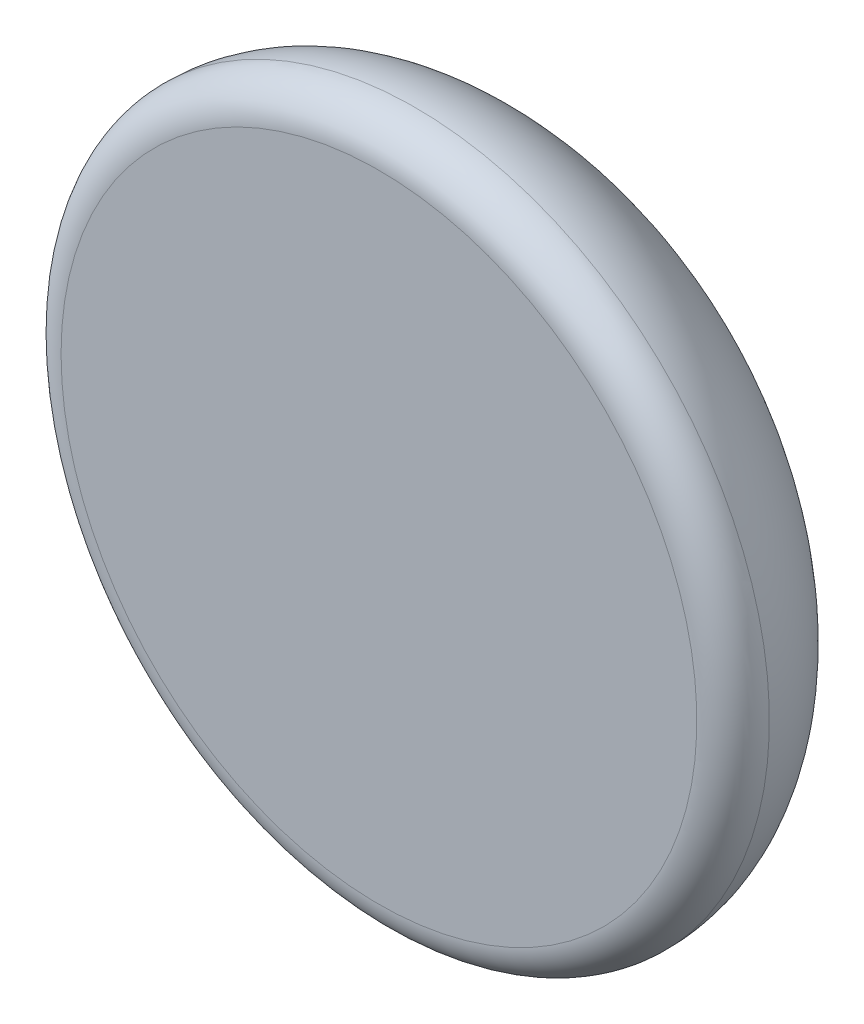
from build123d import *


with BuildPart() as part:
    # Sketch2 → Revolve1 (revolve)
    with BuildSketch(Plane(origin=(0, 0, 0), x_dir=(1, 0, 0), z_dir=(0, 1, 0))):
        with BuildLine():
            Line((-55.65, -6.35), (0, -6.35))
            Line((0, -6.35), (0, 33.65))
            add(Edge.make_bspline(
                [(0, 33.65), (-62, 33.65), (-62, 0)],
                knots=[4.71238898, 4.71238898, 4.71238898, 6.283185307, 6.283185307, 6.283185307], degree=2, weights=[1, 0.707106781, 1]))
            ThreePointArc((-62, 0), (-60.140128061, -4.490128061), (-55.65, -6.35))
        make_face()
    revolve(axis=Axis((0, 0, -33.65), (0, 0, 1)))


solid = part.part
